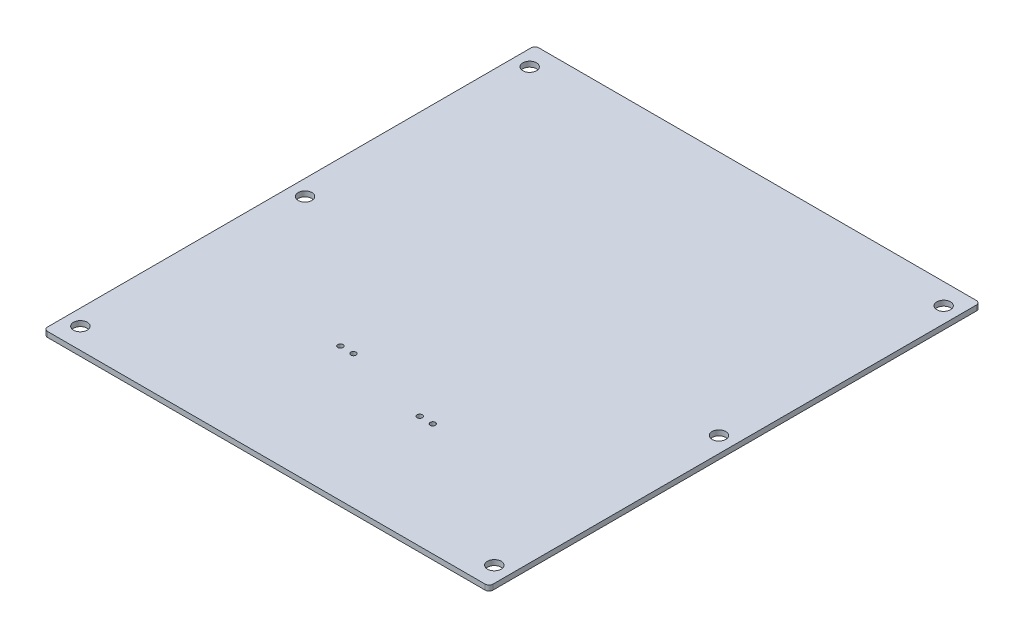
from build123d import *

# Parameters (mm, degrees)
SKETCH1_R           = 2
SKETCH1_R_2         = 5.25
BOSS_EXTRUDE1_DEPTH = 4


with BuildPart() as part:
    # Sketch1 → Boss-Extrude1 (new body)
    with BuildSketch(Plane(origin=(0, 0, 0), x_dir=(1, 0, 0), z_dir=(0, 1, 0))):
        with BuildLine():
            Line((316.226041149, 107.292047617), (316.226041149, -261.707952383))
            ThreePointArc((316.226041149, -261.707952383), (317.104720805, -263.829272726), (319.226041149, -264.707952383))
            Line((319.226041149, -264.707952383), (653.226041149, -264.707952383))
            ThreePointArc((653.226041149, -264.707952383), (655.347361492, -263.829272726), (656.226041149, -261.707952383))
            Line((656.226041149, -261.707952383), (656.226041149, 107.292047617))
            ThreePointArc((656.226041149, 107.292047617), (655.347361492, 109.413367961), (653.226041149, 110.292047617))
            Line((653.226041149, 110.292047617), (319.226041149, 110.292047617))
            ThreePointArc((319.226041149, 110.292047617), (317.104720805, 109.413367961), (316.226041149, 107.292047617))
        make_face()
        with Locations((450.618955235, -162.614244131)):
            Circle(SKETCH1_R, mode=Mode.SUBTRACT)
        with Locations((440.618955235, -162.614244131)):
            Circle(SKETCH1_R, mode=Mode.SUBTRACT)
        with Locations((517.330184073, -178.73741306)):
            Circle(SKETCH1_R, mode=Mode.SUBTRACT)
        with Locations((644.226041149, -77.207952383)):
            Circle(SKETCH1_R_2, mode=Mode.SUBTRACT)
        with Locations((328.226041149, -77.207952383)):
            Circle(SKETCH1_R_2, mode=Mode.SUBTRACT)
        with Locations((644.226041149, 94.292047617)):
            Circle(SKETCH1_R_2, mode=Mode.SUBTRACT)
        with Locations((328.226041149, 94.292047617)):
            Circle(SKETCH1_R_2, mode=Mode.SUBTRACT)
        with Locations((328.226041149, -248.707952383)):
            Circle(SKETCH1_R_2, mode=Mode.SUBTRACT)
        with Locations((644.226041149, -248.707952383)):
            Circle(SKETCH1_R_2, mode=Mode.SUBTRACT)
        with Locations((527.330184073, -178.73741306)):
            Circle(SKETCH1_R, mode=Mode.SUBTRACT)
    extrude(amount=BOSS_EXTRUDE1_DEPTH)


solid = part.part
